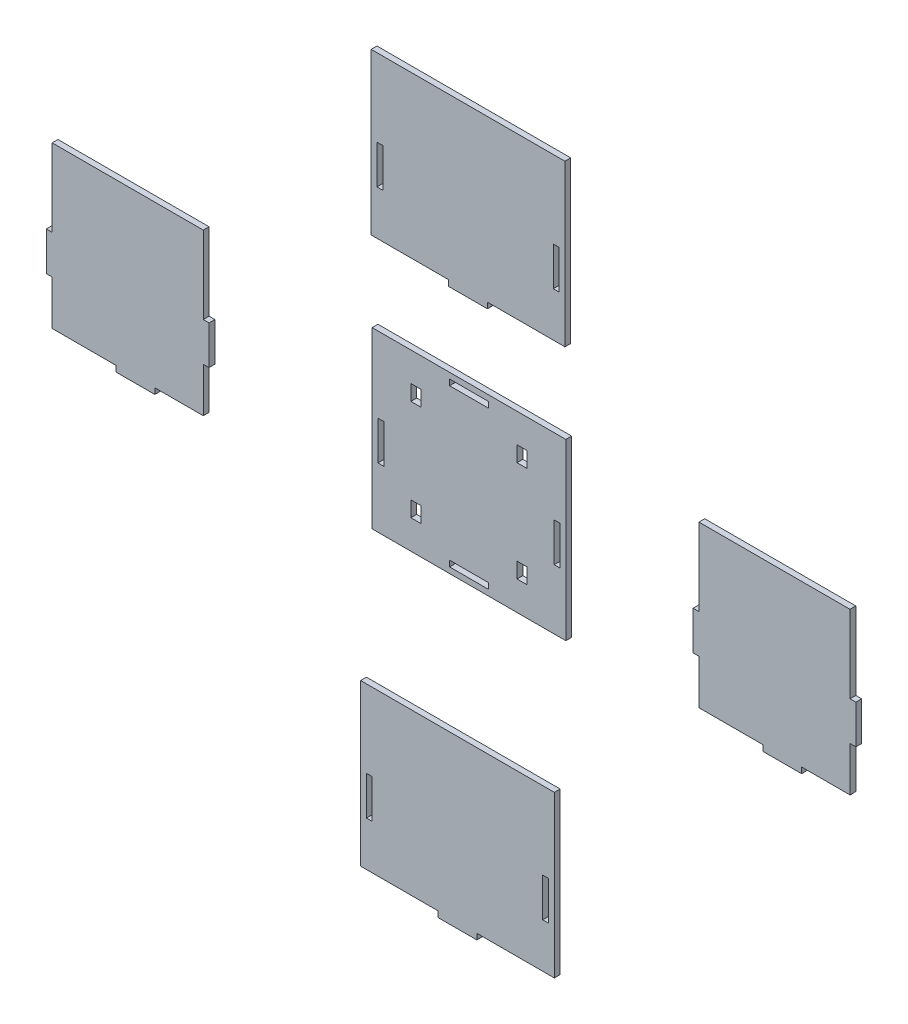
from build123d import *

# Parameters (mm, degrees)
SKETCH_1_W        = 3
SKETCH_1_H        = 20
EXTRUDE_1_DEPTH   = 3
SKETCH_1_W_2      = 100
SKETCH_1_H_2      = 90
SKETCH_1_W_3      = 20
SKETCH_1_H_3      = 3
SKETCH_1_W_4      = 5.2
SKETCH_1_H_4      = 8
EXTRUDE_1_2_DEPTH = 3
EXTRUDE_1_3_DEPTH = 3
EXTRUDE_1_4_DEPTH = 3
EXTRUDE_1_5_DEPTH = 3


with BuildPart() as part:
    # Эскиз1 → Бобышка-Вытянуть1 (new body)
    with BuildSketch(Plane.XY):
        Polygon((-79.423765196, 85.328335351), (-79.423765196, 82.328335351), (-59.423765196, 82.328335351), (-59.423765196, 85.328335351), (-19.423765196, 85.328335351), (-19.423765196, 168.328335351), (-119.423765196, 168.328335351), (-119.423765196, 85.328335351), align=None)
        with Locations((-114.923765196, 118.328335351)):
            Rectangle(SKETCH_1_W, SKETCH_1_H, mode=Mode.SUBTRACT)
        with Locations((-23.923765196, 118.328335351)):
            Rectangle(SKETCH_1_W, SKETCH_1_H, mode=Mode.SUBTRACT)
    extrude(amount=EXTRUDE_1_DEPTH)


with BuildPart() as body_2:
    # Эскиз1 → Extrude 1 2 (new body)
    with BuildSketch(Plane.XY):
        with Locations((-68.934010152, -0.812182741)):
            Rectangle(SKETCH_1_W_2, SKETCH_1_H_2)
        with Locations((-68.934010152, 39.687817259)):
            Rectangle(SKETCH_1_W_3, SKETCH_1_H_3, mode=Mode.SUBTRACT)
        with Locations((-114.434010152, -4.812182741)):
            Rectangle(SKETCH_1_W, SKETCH_1_H, mode=Mode.SUBTRACT)
        with Locations((-68.934010152, -41.312182741)):
            Rectangle(SKETCH_1_W_3, SKETCH_1_H_3, mode=Mode.SUBTRACT)
        with Locations((-23.434010152, -4.812182741)):
            Rectangle(SKETCH_1_W, SKETCH_1_H, mode=Mode.SUBTRACT)
        with Locations((-96.334010152, -26.812182741)):
            Rectangle(SKETCH_1_W_4, SKETCH_1_H_4, mode=Mode.SUBTRACT)
        with Locations((-96.334010152, 25.187817259)):
            Rectangle(SKETCH_1_W_4, SKETCH_1_H_4, mode=Mode.SUBTRACT)
        with Locations((-41.534010152, -26.812182741)):
            Rectangle(SKETCH_1_W_4, SKETCH_1_H_4, mode=Mode.SUBTRACT)
        with Locations((-41.534010152, 25.187817259)):
            Rectangle(SKETCH_1_W_4, SKETCH_1_H_4, mode=Mode.SUBTRACT)
    extrude(amount=EXTRUDE_1_2_DEPTH)


with BuildPart() as body_3:
    # Эскиз1 → Extrude 1 3 (new body)
    with BuildSketch(Plane.XY):
        Polygon((-284.113705584, 44.187817259), (-206.113705584, 44.187817259), (-206.113705584, 4.187817259), (-203.113705584, 4.187817259), (-203.113705584, -15.812182741), (-206.113705584, -15.812182741), (-206.113705584, -38.812182741), (-231.113705584, -38.812182741), (-231.113705584, -41.812182741), (-251.113705584, -41.812182741), (-251.113705584, -38.812182741), (-284.113705584, -38.812182741), (-284.113705584, -15.812182741), (-287.113705584, -15.812182741), (-287.113705584, 4.187817259), (-284.113705584, 4.187817259), align=None)
    extrude(amount=EXTRUDE_1_3_DEPTH)


with BuildPart() as body_4:
    # Эскиз1 → Extrude 1 4 (new body)
    with BuildSketch(Plane.XY):
        Polygon((-124.873096447, -116.564787817), (-24.873096447, -116.564787817), (-24.873096447, -199.564787817), (-64.873096447, -199.564787817), (-64.873096447, -202.564787817), (-84.873096447, -202.564787817), (-84.873096447, -199.564787817), (-124.873096447, -199.564787817), align=None)
        with Locations((-120.373096447, -166.564787817)):
            Rectangle(SKETCH_1_W, SKETCH_1_H, mode=Mode.SUBTRACT)
        with Locations((-29.373096447, -166.564787817)):
            Rectangle(SKETCH_1_W, SKETCH_1_H, mode=Mode.SUBTRACT)
    extrude(amount=EXTRUDE_1_4_DEPTH)


with BuildPart() as body_5:
    # Эскиз1 → Extrude 1 5 (new body)
    with BuildSketch(Plane.XY):
        Polygon((49.773984997, 41.585858004), (127.773984997, 41.585858004), (127.773984997, 1.585858004), (130.773984997, 1.585858004), (130.773984997, -18.414141996), (127.773984997, -18.414141996), (127.773984997, -41.414141996), (102.773984997, -41.414141996), (102.773984997, -44.414141996), (82.773984997, -44.414141996), (82.773984997, -41.414141996), (49.773984997, -41.414141996), (49.773984997, -18.414141996), (46.773984997, -18.414141996), (46.773984997, 1.585858004), (49.773984997, 1.585858004), align=None)
    extrude(amount=EXTRUDE_1_5_DEPTH)


solid = Compound([part.part, body_2.part, body_3.part, body_4.part, body_5.part])
